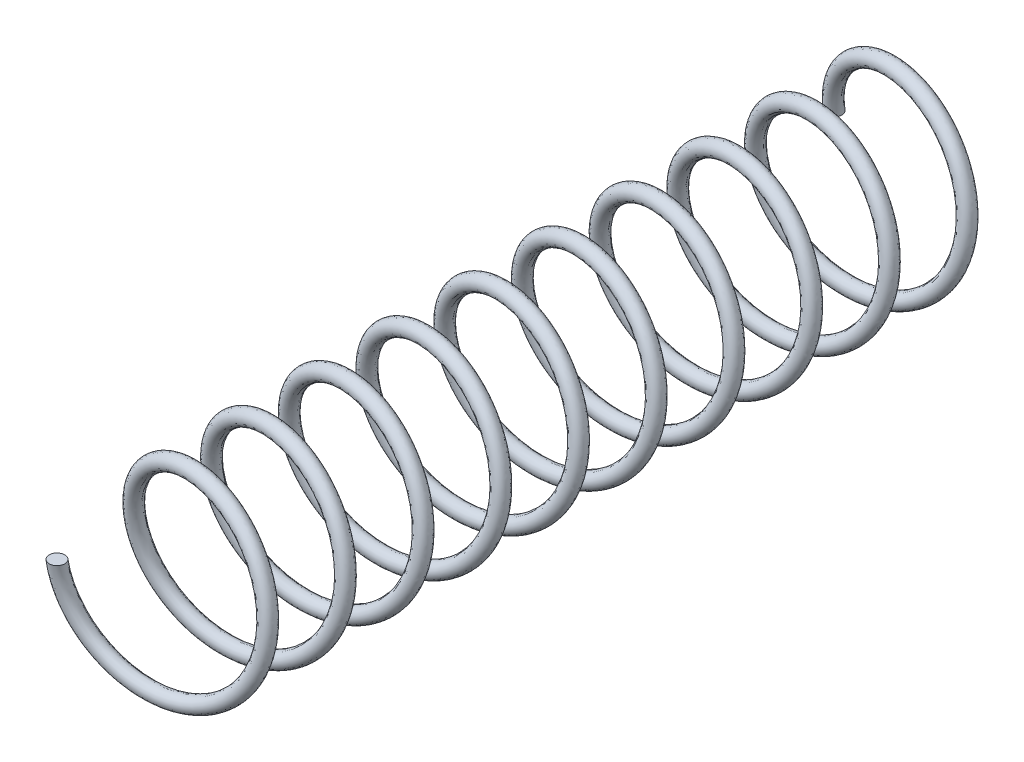
from build123d import *

# Parameters (mm, degrees)
SWEEP1_PITCH       = 5
SWEEP1_HEIGHT      = 50
SWEEP1_RADIUS      = 5.5
SWEEP1_START_ANGLE = -180
SKETCH2_R          = 0.5


with BuildPart() as part:
    # Sweep1: sweep along a helix
    with BuildLine() as sweep1_path:
        add(Helix(SWEEP1_PITCH, SWEEP1_HEIGHT, SWEEP1_RADIUS, center=(0, 0, 0), direction=(0, 0, 1), lefthand=True, mode=Mode.PRIVATE).rotate(Axis((0, 0, 0), (0, 0, 1)), SWEEP1_START_ANGLE))
    # Sketch2 → Sweep1 (sweep)
    with BuildSketch(Plane(origin=(0, 0, 0), x_dir=(1, 0, 0), z_dir=(0, 1, 0))):
        with Locations((-5.5, -50)):
            Circle(SKETCH2_R)
    sweep(path=sweep1_path.line, is_frenet=True)


solid = part.part
